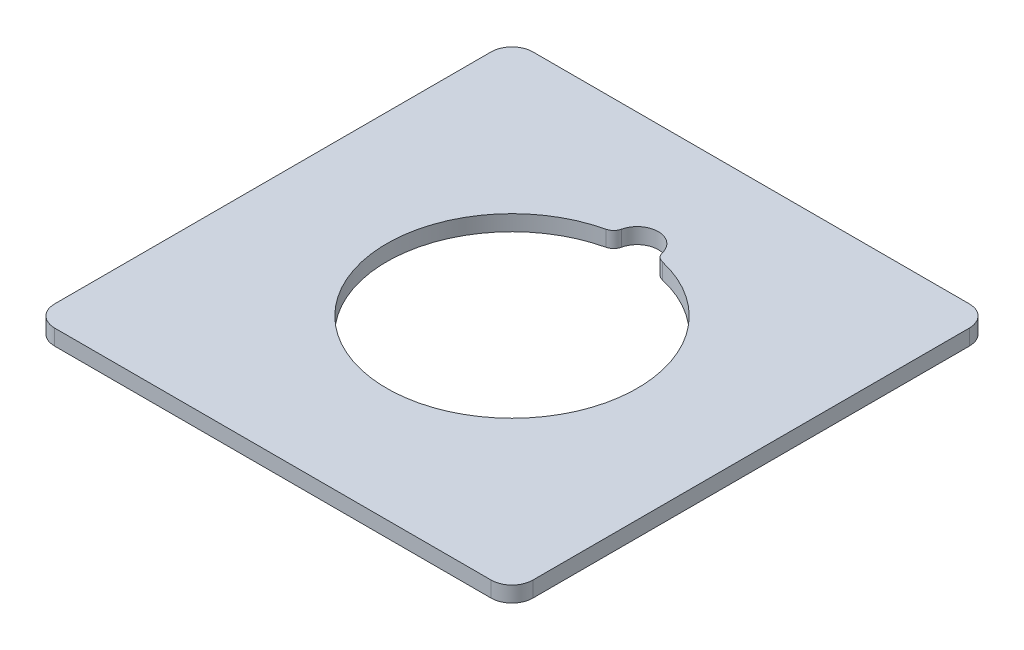
from build123d import *

# Parameters (mm, degrees)
Y_KSEKLIK_EKSTR_ZYON1_DEPTH = 1.5


with BuildPart() as part:
    # Çizim1 → Yükseklik-Ekstrüzyon1 (new body)
    with BuildSketch(Plane(origin=(0, 0, 0), x_dir=(1, 0, 0), z_dir=(0, 1, 0))):
        with BuildLine():
            Line((-20.9, -22.9), (20.9, -22.9))
            ThreePointArc((20.9, -22.9), (22.314213562, -22.314213562), (22.9, -20.9))
            Line((22.9, -20.9), (22.9, 20.9))
            ThreePointArc((22.9, 20.9), (22.314213562, 22.314213562), (20.9, 22.9))
            Line((20.9, 22.9), (-20.9, 22.9))
            ThreePointArc((-20.9, 22.9), (-22.314213562, 22.314213562), (-22.9, 20.9))
            Line((-22.9, 20.9), (-22.9, -20.9))
            ThreePointArc((-22.9, -20.9), (-22.314213562, -22.314213562), (-20.9, -22.9))
        make_face()
        with BuildLine():
            ThreePointArc((-2.705036995, 11.691140871), (0, -12), (2.705036995, 11.691140871))
            ThreePointArc((2.705036995, 11.691140871), (2.222647508, 11.958998982), (1.955748834, 12.441919973))
            ThreePointArc((1.955748834, 12.441919973), (0, 14), (-1.955748834, 12.441919973))
            ThreePointArc((-1.955748834, 12.441919973), (-2.222647508, 11.958998982), (-2.705036995, 11.691140871))
        make_face(mode=Mode.SUBTRACT)
    extrude(amount=Y_KSEKLIK_EKSTR_ZYON1_DEPTH)


solid = part.part
